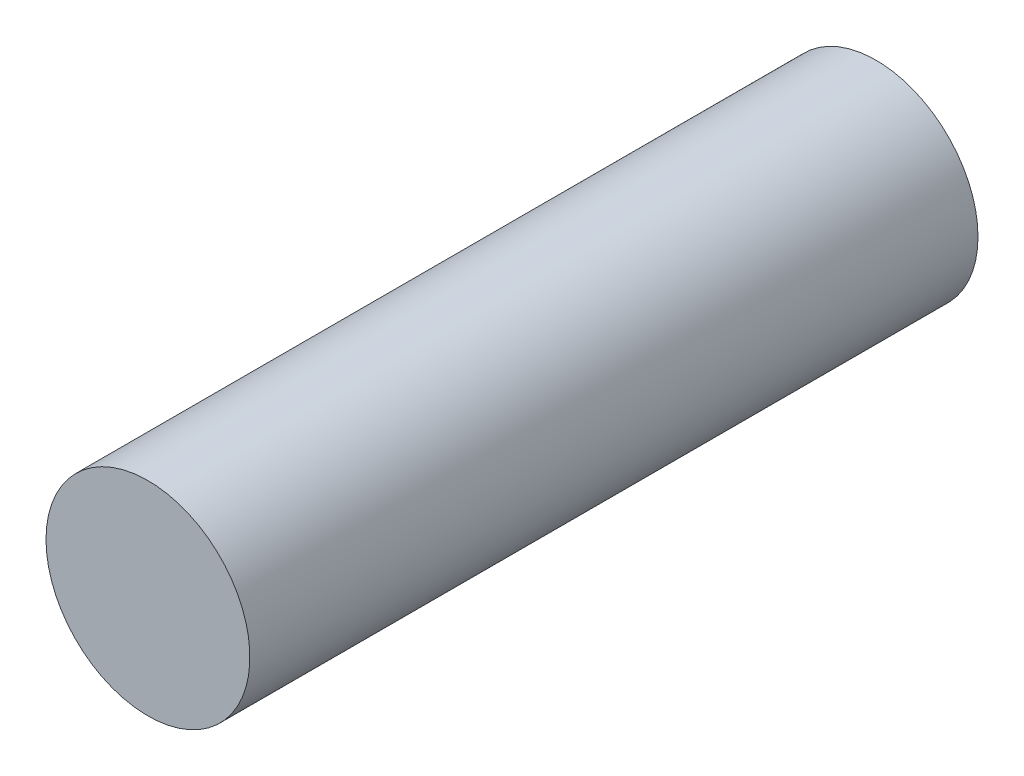
from build123d import *

# Parameters (mm, degrees)
SKETCH2_R           = 3.5
BOSS_EXTRUDE1_DEPTH = 8
SKETCH3_R           = 3.5
BOSS_EXTRUDE2_DEPTH = 18
SKETCH4_W           = 12.5
SKETCH4_H           = 8
SKETCH4_W_2         = 8.5
SKETCH4_H_2         = 4
BOSS_EXTRUDE3_DEPTH = 10
SKETCH5_W           = 12.5
SKETCH5_H           = 8
BOSS_EXTRUDE4_DEPTH = 1
FILLET2_R           = 2
SKETCH6_W           = 15.377134156
SKETCH6_H           = 9.300468084
CUT_EXTRUDE1_DEPTH  = 12


with BuildPart() as part:
    # Sketch2 → Boss-Extrude1 (new body)
    with BuildSketch(Plane.XY):
        Circle(SKETCH2_R)
        with BuildLine():
            Line((-1.237436867, -1.237436867), (1.237436867, -1.237436867))
            ThreePointArc((1.237436867, -1.237436867), (0, 1.75), (-1.237436867, -1.237436867))
        make_face(mode=Mode.SUBTRACT)
    extrude(amount=BOSS_EXTRUDE1_DEPTH)

    # Sketch3 → Boss-Extrude2 (add)
    with BuildSketch(Plane.XY.offset(8)):
        Circle(SKETCH3_R)
    extrude(amount=BOSS_EXTRUDE2_DEPTH)

    # Sketch4 → Boss-Extrude3 (add)
    with BuildSketch(Plane.XY.offset(26)):
        Rectangle(SKETCH4_W, SKETCH4_H)
        Rectangle(SKETCH4_W_2, SKETCH4_H_2, mode=Mode.SUBTRACT)
    extrude(amount=BOSS_EXTRUDE3_DEPTH)

    # Sketch5 → Boss-Extrude4 (add)
    with BuildSketch(Plane(origin=(0, 0, 26), x_dir=(-1, 0, 0), z_dir=(0, 0, -1))):
        Rectangle(SKETCH5_W, SKETCH5_H)
    extrude(amount=BOSS_EXTRUDE4_DEPTH)

    # Fillet2
    fillet2_edges = [part.edges().sort_by_distance(p)[0] for p in [
        (-6.25, -4, 30.5),
        (6.25, -4, 30.5),
        (6.25, 4, 30.5),
        (-6.25, 4, 30.5),
    ]]
    fillet(fillet2_edges, radius=FILLET2_R)

    # Sketch6 → Cut-Extrude1 (cut, through all)
    with BuildSketch(Plane(origin=(0, 0, 25), x_dir=(-1, 0, 0), z_dir=(0, 0, -1))):
        with Locations((-0.478823703, -0.270525698)):
            Rectangle(SKETCH6_W, SKETCH6_H)
    extrude(amount=-CUT_EXTRUDE1_DEPTH, mode=Mode.SUBTRACT)


solid = part.part
